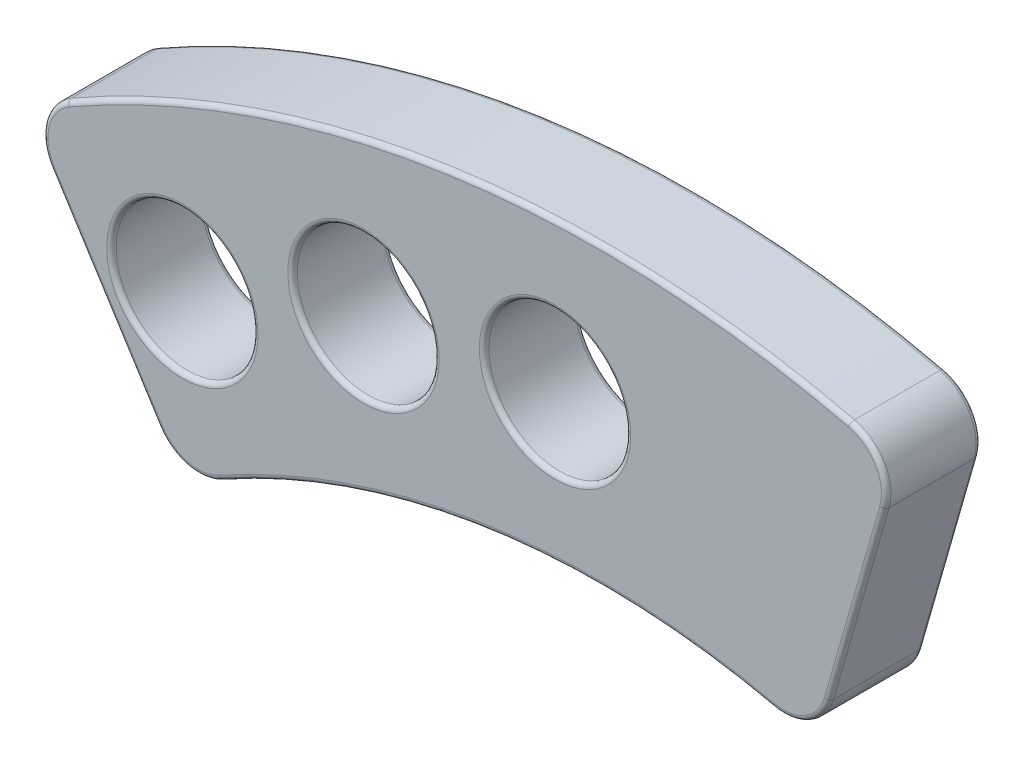
from build123d import *

# Parameters (mm, degrees)
SCHIZZO2_R                   = 3
ESTRUSIONE_ESTRUSIONE3_DEPTH = 4
RACCORDO2_R                  = 0.2


with BuildPart() as part:
    # Schizzo2 → Estrusione-Estrusione3 (new body)
    with BuildSketch(Plane.XY):
        with BuildLine():
            Line((9.622941578, 33.595662152), (11.966595458, 41.777838395))
            ThreePointArc((11.966595458, 41.777838395), (11.770105981, 43.338638999), (10.505661531, 44.274527279))
            ThreePointArc((10.505661531, 44.274527279), (-6.497724988, 45.037564987), (-22.59201682, 39.499410958))
            ThreePointArc((-22.59201682, 39.499410958), (-23.540330925, 38.244373716), (-23.287701565, 36.691667398))
            Line((-23.287701565, 36.691667398), (-18.727178845, 29.505433483))
            ThreePointArc((-18.727178845, 29.505433483), (-17.530420686, 28.638521453), (-16.065115094, 28.829953117))
            ThreePointArc((-16.065115094, 28.829953117), (-4.713039416, 32.665599324), (7.26029322, 32.195376408))
            ThreePointArc((7.26029322, 32.195376408), (8.719971059, 32.425863839), (9.622941578, 33.595662152))
        make_face()
        with Locations((-1.956684159, 39.153410587)):
            Circle(SCHIZZO2_R, mode=Mode.SUBTRACT)
        with Locations((-10.054377712, 37.890997115)):
            Circle(SCHIZZO2_R, mode=Mode.SUBTRACT)
        with Locations((-17.712646712, 34.972565247)):
            Circle(SCHIZZO2_R, mode=Mode.SUBTRACT)
    extrude(amount=ESTRUSIONE_ESTRUSIONE3_DEPTH)

    # Raccordo2
    raccordo2_edges = [part.edges().sort_by_distance(p)[0] for p in [
        (-13.054377712, 37.890997115, 4),
        (8.719971059, 32.425863839, 0),
        (-4.713039416, 32.665599324, 0),
        (-17.530420686, 28.638521453, 0),
        (-21.007440205, 33.098550441, 0),
        (-23.540343413, 38.244323318, 0),
        (-6.497724988, 45.037564987, 0),
        (11.770105981, 43.338638999, 0),
        (10.794768518, 37.686750273, 0),
        (-20.712646712, 34.972565247, 4),
        (-20.712646712, 34.972565247, 0),
        (-13.054377712, 37.890997115, 0),
        (-4.956684159, 39.153410587, 0),
        (10.794768518, 37.686750273, 4),
        (11.770105981, 43.338638999, 4),
        (-6.497724988, 45.037564987, 4),
        (-23.540343413, 38.244323318, 4),
        (-21.007440205, 33.098550441, 4),
        (-17.530420686, 28.638521453, 4),
        (-4.713039416, 32.665599324, 4),
        (8.719971059, 32.425863839, 4),
        (-4.956684159, 39.153410587, 4),
    ]]
    fillet(raccordo2_edges, radius=RACCORDO2_R)


solid = part.part
